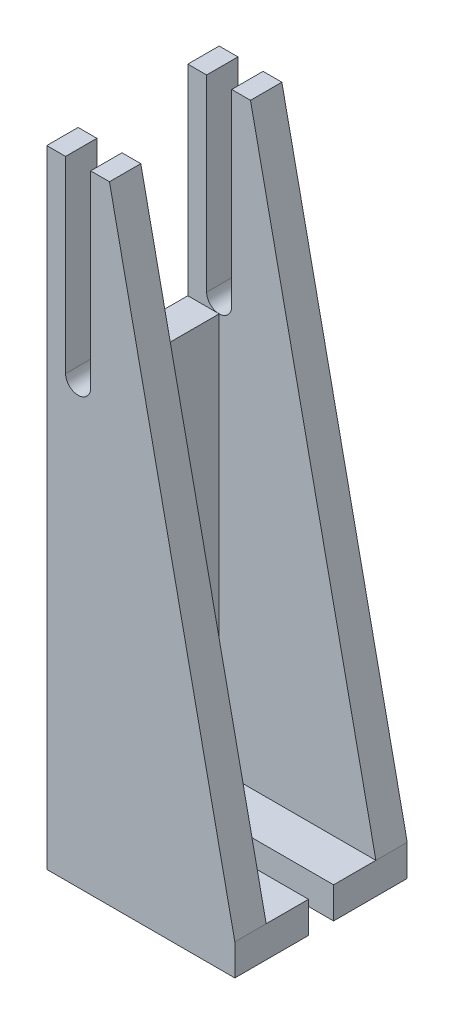
from build123d import *

# Parameters (mm, degrees)
SALIENTE_EXTRUIR1_DEPTH = 55
CORTAR_EXTRUIR1_DEPTH   = 50
CROQUIS4_W              = 35
CROQUIS4_H              = 6.173291601
CORTAR_EXTRUIR2_DEPTH   = 30.5
CORTAR_EXTRUIR3_DEPTH   = 30.5


with BuildPart() as part:
    # Croquis1 → Saliente-Extruir1 (new body)
    with BuildSketch(Plane.XY):
        with BuildLine():
            Line((-28.119282629, 36.435094891), (-28.119282629, -163.564905109))
            Line((-28.119282629, -163.564905109), (31.880717371, -163.564905109))
            Line((31.880717371, -163.564905109), (31.880717371, -153.564905109))
            Line((31.880717371, -153.564905109), (-8.119282629, 36.435094891))
            Line((-8.119282629, 36.435094891), (-14.119282629, 36.435094891))
            Line((-14.119282629, 36.435094891), (-14.119282629, -23.564905109))
            ThreePointArc((-14.119282629, -23.564905109), (-18.119282629, -27.564905109), (-22.119282629, -23.564905109))
            Line((-22.119282629, -23.564905109), (-22.119282629, 36.435094891))
            Line((-22.119282629, 36.435094891), (-28.119282629, 36.435094891))
        make_face()
    extrude(amount=SALIENTE_EXTRUIR1_DEPTH)

    # Croquis2 → Cortar-Extruir1 (cut)
    with BuildSketch(Plane(origin=(31.880717371, 0, 0), x_dir=(0, 0, -1), z_dir=(1, 0, 0))):
        Polygon((-45, -142.180293539), (-45, -153.564905109), (-27.5, -153.564905109), (-10, -153.564905109), (-10, -142.180293539), (-10, 41.509822178), (-45, 41.509822178), align=None)
    extrude(amount=-CORTAR_EXTRUIR1_DEPTH, mode=Mode.SUBTRACT)

    # Croquis4 → Cortar-Extruir2 (cut)
    with BuildSketch(Plane.ZY.offset(28.119282629)):
        with Locations((27.5, 39.521740691)):
            Rectangle(CROQUIS4_W, CROQUIS4_H)
        Polygon((10, -27.564905109), (27.5, -27.564905109), (45, -27.564905109), (45, 36.435094891), (10, 36.435094891), align=None)
    extrude(amount=-CORTAR_EXTRUIR2_DEPTH, mode=Mode.SUBTRACT)

    # Croquis5 → Cortar-Extruir3 (cut)
    with BuildSketch(Plane(origin=(0, -163.564905109, 0), x_dir=(-1, 0, 0), z_dir=(0, -1, 0))):
        with BuildLine():
            Line((-31.880717371, -27.5), (-31.880717371, -31.5))
            Line((-31.880717371, -31.5), (14.119282629, -31.5))
            ThreePointArc((14.119282629, -31.5), (18.119282629, -27.5), (14.119282629, -23.5))
            Line((14.119282629, -23.5), (-31.880717371, -23.5))
            Line((-31.880717371, -23.5), (-31.880717371, -27.5))
        make_face()
    extrude(amount=-CORTAR_EXTRUIR3_DEPTH, mode=Mode.SUBTRACT)


solid = part.part
